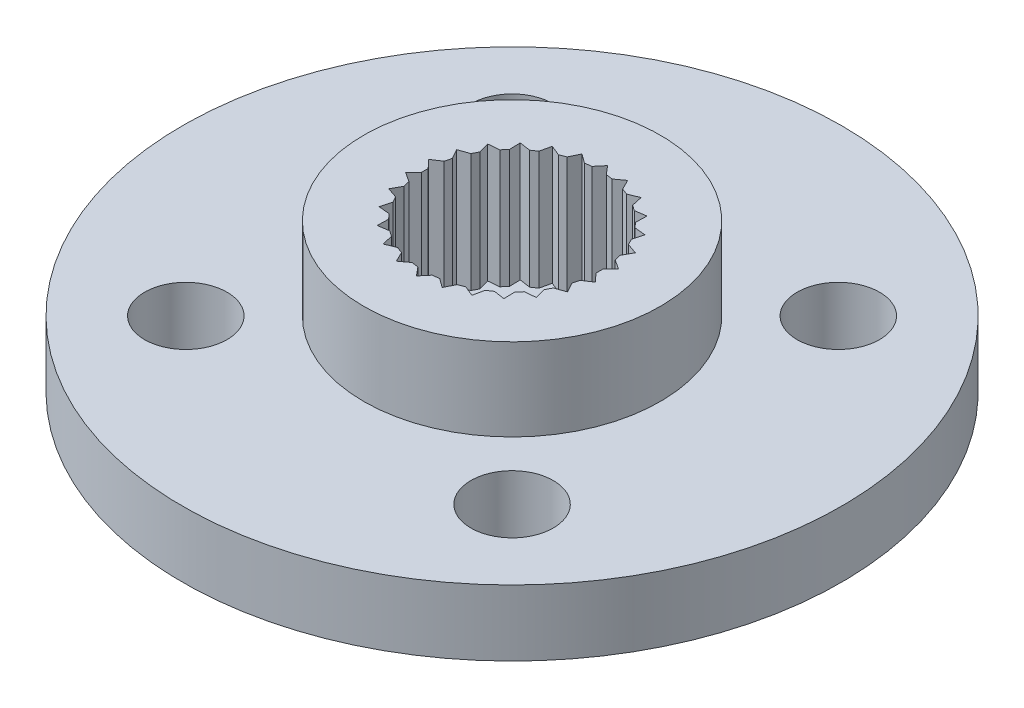
from build123d import *

# Parameters (mm, degrees)
SKETCH_1_W              = 10
SKETCH_1_H              = 2
SKETCH_2_R              = 4.5
EXTRUDE_1_DEPTH         = 2.5
CUT_EXTRUDE_1_DEPTH     = 3.6
HOLE_WIZARD_3_0_3_1_D   = 3
HOLE_WIZARD_2_5_2_5_1_D = 2.5
CHAMFER_1_SIZE          = 0.140560122
CHAMFER_1_EDGE_2_SIZE   = 0.140560122
CHAMFER_1_EDGE_3_SIZE   = 0.140560122
CHAMFER_1_EDGE_4_SIZE   = 0.140560122
CHAMFER_1_EDGE_5_SIZE   = 0.140560122
CHAMFER_1_EDGE_6_SIZE   = 0.140560122
CHAMFER_1_EDGE_7_SIZE   = 0.140560122
CHAMFER_1_EDGE_8_SIZE   = 0.140560122
CHAMFER_1_EDGE_9_SIZE   = 0.140560122
CHAMFER_1_EDGE_10_SIZE  = 0.140560122
CHAMFER_1_EDGE_11_SIZE  = 0.140560122
CHAMFER_1_EDGE_12_SIZE  = 0.140560122
CHAMFER_1_EDGE_13_SIZE  = 0.140560122
CHAMFER_1_EDGE_14_SIZE  = 0.140560122
CHAMFER_1_EDGE_15_SIZE  = 0.140560122
CHAMFER_1_EDGE_16_SIZE  = 0.140560122
CHAMFER_1_EDGE_17_SIZE  = 0.140560122
CHAMFER_1_EDGE_18_SIZE  = 0.140560122
CHAMFER_1_EDGE_19_SIZE  = 0.140560122
CHAMFER_1_EDGE_20_SIZE  = 0.140560122
CHAMFER_1_EDGE_21_SIZE  = 0.140560122
CHAMFER_1_EDGE_22_SIZE  = 0.140560122
CHAMFER_1_EDGE_23_SIZE  = 0.140560122
CHAMFER_1_EDGE_24_SIZE  = 0.140560122
CHAMFER_1_EDGE_25_SIZE  = 0.140560122
CHAMFER_1_EDGE_26_SIZE  = 0.140560122


with BuildPart() as part:
    # Эскиз1 → Повернуть1 (revolve)
    with BuildSketch(Plane.XY, mode=Mode.PRIVATE) as revolve_1_sk:
        with Locations((5, 1)):
            Rectangle(SKETCH_1_W, SKETCH_1_H)
    revolve(revolve_1_sk.sketch.rotate(Axis((0, 2, 0), (0, -1, 0)), 270), axis=Axis((0, 2, 0), (0, -1, 0)))

    # Эскиз2 → Бобышка-Вытянуть1 (add)
    with BuildSketch(Plane(origin=(0, 2, 0), x_dir=(-1, 0, 0), z_dir=(0, 1, 0))):
        with Locations(Location((0, 0, 0), (0, 0, 90))):
            Circle(SKETCH_2_R)
    extrude(amount=EXTRUDE_1_DEPTH)

    # Эскиз3 → Вырез-Вытянуть1 (cut)
    with BuildSketch(Plane(origin=(0, 4.5, 0), x_dir=(-1, 0, 0), z_dir=(0, 1, 0))):
        Polygon((-2.711547104, 1.028354172), (-2.477853855, 0.610736123), (-2.878855735, 0.349556373), (-2.552010646, 0), (-2.878855735, -0.349556373), (-2.477853855, -0.610736123), (-2.711547104, -1.028354172), (-2.259693204, -1.185978483), (-2.386653211, -1.647387766), (-1.910207398, -1.692296084), (-1.923055709, -2.17068117), (-1.449707281, -2.100263587), (-1.347697199, -2.567822474), (-0.904955447, -2.386171406), (-0.694015426, -2.815731271), (-0.307610891, -2.533403615), (0, -2.9), (0.307610891, -2.533403615), (0.694015426, -2.815731271), (0.904955447, -2.386171406), (1.347697199, -2.567822474), (1.449707281, -2.100263587), (1.923055709, -2.17068117), (1.910207398, -1.692296084), (2.386653211, -1.647387766), (2.259693204, -1.185978483), (2.711547104, -1.028354172), (2.477853855, -0.610736123), (2.878855735, -0.349556373), (2.552010646, 0), (2.878855735, 0.349556373), (2.477853855, 0.610736123), (2.711547104, 1.028354172), (2.259693204, 1.185978483), (2.386653211, 1.647387766), (1.910207398, 1.692296084), (1.923055709, 2.17068117), (1.449707281, 2.100263587), (1.347697199, 2.567822474), (0.904955447, 2.386171406), (0.694015426, 2.815731271), (0.307610891, 2.533403615), (0, 2.9), (-0.307610891, 2.533403615), (-0.694015426, 2.815731271), (-0.904955447, 2.386171406), (-1.347697199, 2.567822474), (-1.449707281, 2.100263587), (-1.923055709, 2.17068117), (-1.910207398, 1.692296084), (-2.386653211, 1.647387766), (-2.259693204, 1.185978483), align=None)
    extrude(amount=-CUT_EXTRUDE_1_DEPTH, mode=Mode.SUBTRACT)

    # Диаметр отверстия Ø3.0 (3)1 (through all)
    with Locations(Plane(origin=(0, 0.9, 0), x_dir=(1, 0, 0), z_dir=(0, 1, 0))):
        with Locations((0, 0)):
            Hole(HOLE_WIZARD_3_0_3_1_D / 2)

    # Диаметр отверстия Ø2.5 (2.5)1 (through all)
    with Locations(Plane(origin=(0, 2, 0), x_dir=(1, 0, 0), z_dir=(0, 1, 0))):
        with Locations((-4.949747468, 4.949747468), (4.949747468, 4.949747468), (4.949747468, -4.949747468), (-4.949747468, -4.949747468)):
            Hole(HOLE_WIZARD_2_5_2_5_1_D / 2)

    # Фаска1
    chamfer_1_edges = [part.edges().sort_by_distance(p)[0] for p in [
        (2.259693204, 2.7, 1.185978483),
    ]]
    chamfer(chamfer_1_edges, length=CHAMFER_1_SIZE)

    # Фаска1 edge 2
    chamfer_1_edge_2_edges = [part.edges().sort_by_distance(p)[0] for p in [
        (1.910207398, 2.7, 1.692296084),
    ]]
    chamfer(chamfer_1_edge_2_edges, length=CHAMFER_1_EDGE_2_SIZE)

    # Фаска1 edge 3
    chamfer_1_edge_3_edges = [part.edges().sort_by_distance(p)[0] for p in [
        (1.449707281, 2.7, 2.100263587),
    ]]
    chamfer(chamfer_1_edge_3_edges, length=CHAMFER_1_EDGE_3_SIZE)

    # Фаска1 edge 4
    chamfer_1_edge_4_edges = [part.edges().sort_by_distance(p)[0] for p in [
        (0.904955447, 2.7, 2.386171406),
    ]]
    chamfer(chamfer_1_edge_4_edges, length=CHAMFER_1_EDGE_4_SIZE)

    # Фаска1 edge 5
    chamfer_1_edge_5_edges = [part.edges().sort_by_distance(p)[0] for p in [
        (0.307610891, 2.7, 2.533403615),
    ]]
    chamfer(chamfer_1_edge_5_edges, length=CHAMFER_1_EDGE_5_SIZE)

    # Фаска1 edge 6
    chamfer_1_edge_6_edges = [part.edges().sort_by_distance(p)[0] for p in [
        (-0.307610891, 2.7, 2.533403615),
    ]]
    chamfer(chamfer_1_edge_6_edges, length=CHAMFER_1_EDGE_6_SIZE)

    # Фаска1 edge 7
    chamfer_1_edge_7_edges = [part.edges().sort_by_distance(p)[0] for p in [
        (-0.904955447, 2.7, 2.386171406),
    ]]
    chamfer(chamfer_1_edge_7_edges, length=CHAMFER_1_EDGE_7_SIZE)

    # Фаска1 edge 8
    chamfer_1_edge_8_edges = [part.edges().sort_by_distance(p)[0] for p in [
        (-1.449707281, 2.7, 2.100263587),
    ]]
    chamfer(chamfer_1_edge_8_edges, length=CHAMFER_1_EDGE_8_SIZE)

    # Фаска1 edge 9
    chamfer_1_edge_9_edges = [part.edges().sort_by_distance(p)[0] for p in [
        (-1.910207398, 2.7, 1.692296084),
    ]]
    chamfer(chamfer_1_edge_9_edges, length=CHAMFER_1_EDGE_9_SIZE)

    # Фаска1 edge 10
    chamfer_1_edge_10_edges = [part.edges().sort_by_distance(p)[0] for p in [
        (-2.259693204, 2.7, 1.185978483),
    ]]
    chamfer(chamfer_1_edge_10_edges, length=CHAMFER_1_EDGE_10_SIZE)

    # Фаска1 edge 11
    chamfer_1_edge_11_edges = [part.edges().sort_by_distance(p)[0] for p in [
        (-2.477853855, 2.7, 0.610736123),
    ]]
    chamfer(chamfer_1_edge_11_edges, length=CHAMFER_1_EDGE_11_SIZE)

    # Фаска1 edge 12
    chamfer_1_edge_12_edges = [part.edges().sort_by_distance(p)[0] for p in [
        (-2.552010646, 2.7, 0),
    ]]
    chamfer(chamfer_1_edge_12_edges, length=CHAMFER_1_EDGE_12_SIZE)

    # Фаска1 edge 13
    chamfer_1_edge_13_edges = [part.edges().sort_by_distance(p)[0] for p in [
        (-2.477853855, 2.7, -0.610736123),
    ]]
    chamfer(chamfer_1_edge_13_edges, length=CHAMFER_1_EDGE_13_SIZE)

    # Фаска1 edge 14
    chamfer_1_edge_14_edges = [part.edges().sort_by_distance(p)[0] for p in [
        (-2.259693204, 2.7, -1.185978483),
    ]]
    chamfer(chamfer_1_edge_14_edges, length=CHAMFER_1_EDGE_14_SIZE)

    # Фаска1 edge 15
    chamfer_1_edge_15_edges = [part.edges().sort_by_distance(p)[0] for p in [
        (-1.910207398, 2.7, -1.692296084),
    ]]
    chamfer(chamfer_1_edge_15_edges, length=CHAMFER_1_EDGE_15_SIZE)

    # Фаска1 edge 16
    chamfer_1_edge_16_edges = [part.edges().sort_by_distance(p)[0] for p in [
        (-1.449707281, 2.7, -2.100263587),
    ]]
    chamfer(chamfer_1_edge_16_edges, length=CHAMFER_1_EDGE_16_SIZE)

    # Фаска1 edge 17
    chamfer_1_edge_17_edges = [part.edges().sort_by_distance(p)[0] for p in [
        (-0.904955447, 2.7, -2.386171406),
    ]]
    chamfer(chamfer_1_edge_17_edges, length=CHAMFER_1_EDGE_17_SIZE)

    # Фаска1 edge 18
    chamfer_1_edge_18_edges = [part.edges().sort_by_distance(p)[0] for p in [
        (-0.307610891, 2.7, -2.533403615),
    ]]
    chamfer(chamfer_1_edge_18_edges, length=CHAMFER_1_EDGE_18_SIZE)

    # Фаска1 edge 19
    chamfer_1_edge_19_edges = [part.edges().sort_by_distance(p)[0] for p in [
        (0.307610891, 2.7, -2.533403615),
    ]]
    chamfer(chamfer_1_edge_19_edges, length=CHAMFER_1_EDGE_19_SIZE)

    # Фаска1 edge 20
    chamfer_1_edge_20_edges = [part.edges().sort_by_distance(p)[0] for p in [
        (0.904955447, 2.7, -2.386171406),
    ]]
    chamfer(chamfer_1_edge_20_edges, length=CHAMFER_1_EDGE_20_SIZE)

    # Фаска1 edge 21
    chamfer_1_edge_21_edges = [part.edges().sort_by_distance(p)[0] for p in [
        (1.449707281, 2.7, -2.100263587),
    ]]
    chamfer(chamfer_1_edge_21_edges, length=CHAMFER_1_EDGE_21_SIZE)

    # Фаска1 edge 22
    chamfer_1_edge_22_edges = [part.edges().sort_by_distance(p)[0] for p in [
        (1.910207398, 2.7, -1.692296084),
    ]]
    chamfer(chamfer_1_edge_22_edges, length=CHAMFER_1_EDGE_22_SIZE)

    # Фаска1 edge 23
    chamfer_1_edge_23_edges = [part.edges().sort_by_distance(p)[0] for p in [
        (2.259693204, 2.7, -1.185978483),
    ]]
    chamfer(chamfer_1_edge_23_edges, length=CHAMFER_1_EDGE_23_SIZE)

    # Фаска1 edge 24
    chamfer_1_edge_24_edges = [part.edges().sort_by_distance(p)[0] for p in [
        (2.477853855, 2.7, -0.610736123),
    ]]
    chamfer(chamfer_1_edge_24_edges, length=CHAMFER_1_EDGE_24_SIZE)

    # Фаска1 edge 25
    chamfer_1_edge_25_edges = [part.edges().sort_by_distance(p)[0] for p in [
        (2.552010646, 2.7, 0),
    ]]
    chamfer(chamfer_1_edge_25_edges, length=CHAMFER_1_EDGE_25_SIZE)

    # Фаска1 edge 26
    chamfer_1_edge_26_edges = [part.edges().sort_by_distance(p)[0] for p in [
        (2.477853855, 2.7, 0.610736123),
    ]]
    chamfer(chamfer_1_edge_26_edges, length=CHAMFER_1_EDGE_26_SIZE)


solid = part.part
